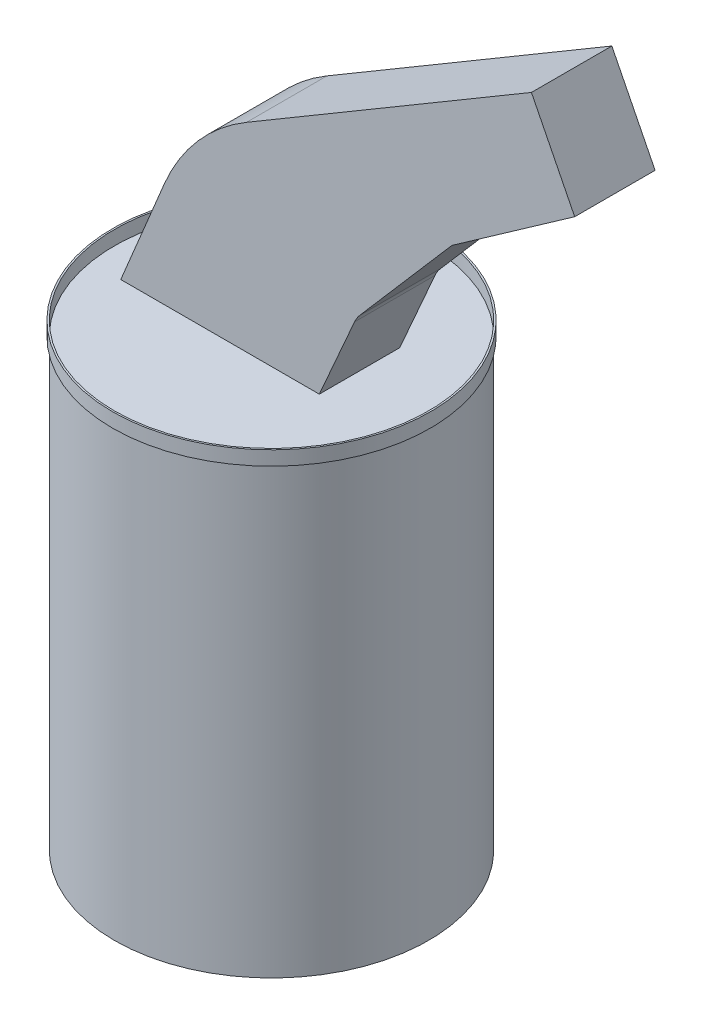
from build123d import *

# Parameters (mm, degrees)
SKETCH2_R           = 47.5
BOSS_EXTRUDE1_DEPTH = 67.15
SKETCH3_R           = 48
SKETCH3_R_2         = 47.5
BOSS_EXTRUDE2_DEPTH = 4.3
BOSS_EXTRUDE3_DEPTH = 12.15


with BuildPart() as part:
    # Sketch2 → Boss-Extrude1 (new body, symmetric)
    with BuildSketch(Plane(origin=(0, 0, 0), x_dir=(1, 0, 0), z_dir=(0, 1, 0))):
        Circle(SKETCH2_R)
    extrude(amount=BOSS_EXTRUDE1_DEPTH, both=True)


with BuildPart() as body_2:
    # Sketch3 → Boss-Extrude2 (new body)
    with BuildSketch(Plane(origin=(0, 67.15, 0), x_dir=(1, 0, 0), z_dir=(0, 1, 0))):
        Circle(SKETCH3_R)
        Circle(SKETCH3_R_2, mode=Mode.SUBTRACT)
    extrude(amount=BOSS_EXTRUDE2_DEPTH)


with BuildPart() as body_3:
    # Sketch4 → Boss-Extrude3 (new body, symmetric)
    with BuildSketch(Plane.XY):
        with BuildLine():
            Line((103.774602703, 156.469061848), (90.704504596, 182.475870743))
            Line((90.704504596, 182.475870743), (4.608125409, 131.609246215))
            ThreePointArc((4.608125409, 131.609246215), (-10.144984286, 119.325875242), (-20.263444967, 103.01170344))
            Line((-20.263444967, 103.01170344), (-33.403029121, 71.45))
            Line((-33.403029121, 71.45), (26.596970879, 71.45))
            Line((26.596970879, 71.45), (37.246730037, 95.700020494))
            ThreePointArc((37.246730037, 95.700020494), (37.947277501, 97.018131489), (38.836227203, 98.217277755))
            Line((38.836227203, 98.217277755), (66.653981734, 130.409777174))
            Line((66.653981734, 130.409777174), (103.774602703, 156.469061848))
        make_face()
    extrude(amount=BOSS_EXTRUDE3_DEPTH, both=True)


solid = Compound([part.part, body_2.part, body_3.part])
